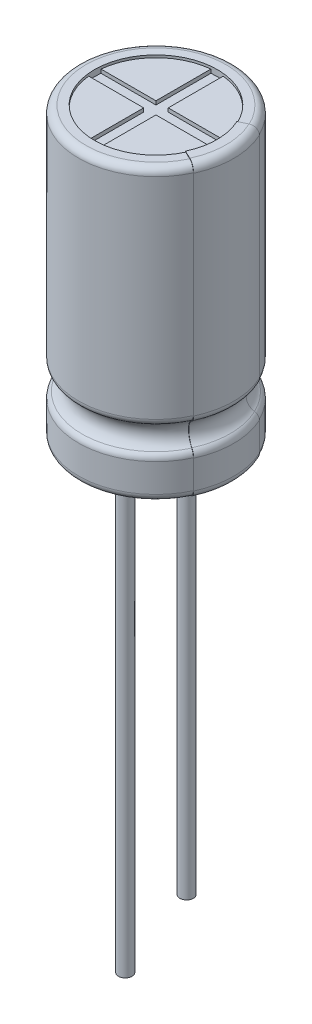
from build123d import *

# Parameters (mm, degrees)
BOSS_EXTRUDE1_DEPTH      = 0.15
BOSS_EXTRUDE1_2_DEPTH    = 0.15
BOSS_EXTRUDE1_3_DEPTH    = 0.15
BOSS_EXTRUDE1_4_DEPTH    = 0.15
SKETCH3_R                = 1.8
SKETCH3_RX               = 1.67
SKETCH3_RY               = 0.9
BOSS_EXTRUDE2_DEPTH      = 0.6
REVOLVE3_ANGLE           = 25
REVOLVE3_OTHER_WAY_ANGLE = 25
SKETCH7_R                = 0.275
BOSS_EXTRUDE3_DEPTH      = 19.6
SKETCH7_4_R              = 0.275
BOSS_EXTRUDE4_DEPTH      = 15.6


with BuildPart() as part:
    # Sketch1 → Revolve1 (revolve)
    with BuildSketch(Plane.XY, mode=Mode.PRIVATE) as revolve1_sk:
        with BuildLine():
            Line((0, 0.6), (2.55, 0.6))
            Line((2.55, 0.6), (2.55, 0.4))
            Line((2.55, 0.4), (2.85, 0.4))
            ThreePointArc((2.85, 0.4), (3.062132034, 0.487867966), (3.15, 0.7))
            Line((3.15, 0.7), (3.15, 1.856893734))
            ThreePointArc((3.15, 1.856893734), (3.113127589, 2.000990479), (3.011574188, 2.109665928))
            ThreePointArc((3.011574188, 2.109665928), (2.7430522, 2.6), (3.011574188, 3.090334072))
            ThreePointArc((3.011574188, 3.090334072), (3.113127589, 3.199009521), (3.15, 3.343106266))
            Line((3.15, 3.343106266), (3.15, 11.9))
            ThreePointArc((3.15, 11.9), (3.062132034, 12.112132034), (2.85, 12.2))
            Line((2.85, 12.2), (2.5, 12.2))
            Line((2.5, 12.2), (2.5, 11.95))
            Line((2.5, 11.95), (0, 11.95))
            Line((0, 11.95), (0, 0.6))
        make_face()
    revolve(revolve1_sk.sketch.rotate(Axis((0, 11.95, 0), (0, -1, 0)), 180), axis=Axis((0, 11.95, 0), (0, -1, 0)))



with BuildPart() as body_2:
    # Sketch2 → Boss-Extrude1 (new body)
    with BuildSketch(Plane(origin=(0, 11.95, 0), x_dir=(1, 0, 0), z_dir=(0, 1, 0))):
        with BuildLine():
            Line((-0.25, 0.25), (-0.25, 2.487468593))
            ThreePointArc((-0.25, 2.487468593), (-1.767766953, 1.767766953), (-2.487468593, 0.25))
            Line((-2.487468593, 0.25), (-0.25, 0.25))
        make_face()
    extrude(amount=BOSS_EXTRUDE1_DEPTH)


with BuildPart() as body_3:
    # Sketch2 → Boss-Extrude1 2 (new body)
    with BuildSketch(Plane(origin=(0, 11.95, 0), x_dir=(1, 0, 0), z_dir=(0, 1, 0))):
        with BuildLine():
            Line((0.25, -2.487468593), (0.25, -0.25))
            Line((0.25, -0.25), (2.487468593, -0.25))
            ThreePointArc((2.487468593, -0.25), (1.767766953, -1.767766953), (0.25, -2.487468593))
        make_face()
    extrude(amount=BOSS_EXTRUDE1_2_DEPTH)


with BuildPart() as body_4:
    # Sketch2 → Boss-Extrude1 3 (new body)
    with BuildSketch(Plane(origin=(0, 11.95, 0), x_dir=(1, 0, 0), z_dir=(0, 1, 0))):
        with BuildLine():
            Line((-0.25, -2.487468593), (-0.25, -0.25))
            Line((-0.25, -0.25), (-2.487468593, -0.25))
            ThreePointArc((-2.487468593, -0.25), (-1.767766953, -1.767766953), (-0.25, -2.487468593))
        make_face()
    extrude(amount=BOSS_EXTRUDE1_3_DEPTH)


with BuildPart() as body_5:
    # Sketch2 → Boss-Extrude1 4 (new body)
    with BuildSketch(Plane(origin=(0, 11.95, 0), x_dir=(1, 0, 0), z_dir=(0, 1, 0))):
        with BuildLine():
            Line((0.25, 0.25), (0.25, 2.487468593))
            ThreePointArc((0.25, 2.487468593), (1.767766953, 1.767766953), (2.487468593, 0.25))
            Line((2.487468593, 0.25), (0.25, 0.25))
        make_face()
    extrude(amount=BOSS_EXTRUDE1_4_DEPTH)


with BuildPart() as body_6:
    # Sketch3 → Boss-Extrude2 (new body)
    with BuildSketch(Plane.XZ.offset(-0.6)):
        Circle(SKETCH3_R)
        with Locations(Location((0, 0), (0, 0, 180))):
            Ellipse(SKETCH3_RX, SKETCH3_RY, mode=Mode.SUBTRACT)
    extrude(amount=BOSS_EXTRUDE2_DEPTH)


with BuildPart() as body_7:
    # Sketch5 → Revolve3 (revolve)
    with BuildSketch(Plane.XY):
        with BuildLine():
            Line((2.479915075, 12.22), (2.530084566, 0.38))
            Line((2.530084566, 0.38), (2.85, 0.38))
            ThreePointArc((2.85, 0.38), (3.07627417, 0.47372583), (3.17, 0.7))
            Line((3.17, 0.7), (3.17, 1.856893734))
            ThreePointArc((3.17, 1.856893734), (3.130669429, 2.010596928), (3.022345801, 2.126517407))
            ThreePointArc((3.022345801, 2.126517407), (2.7630522, 2.6), (3.022345801, 3.073482593))
            ThreePointArc((3.022345801, 3.073482593), (3.130669429, 3.189403072), (3.17, 3.343106266))
            Line((3.17, 3.343106266), (3.17, 11.9))
            ThreePointArc((3.17, 11.9), (3.07627417, 12.12627417), (2.85, 12.22))
            Line((2.85, 12.22), (2.479915075, 12.22))
        make_face()
        with BuildLine():
            Line((2.5, 12.2), (2.85, 12.2))
            ThreePointArc((2.85, 12.2), (3.062132034, 12.112132034), (3.15, 11.9))
            Line((3.15, 11.9), (3.15, 3.343106266))
            ThreePointArc((3.15, 3.343106266), (3.113127589, 3.199009521), (3.011574188, 3.090334072))
            ThreePointArc((3.011574188, 3.090334072), (2.7430522, 2.6), (3.011574188, 2.109665928))
            ThreePointArc((3.011574188, 2.109665928), (3.113127589, 2.000990479), (3.15, 1.856893734))
            Line((3.15, 1.856893734), (3.15, 0.7))
            ThreePointArc((3.15, 0.7), (3.062132034, 0.487867966), (2.85, 0.4))
            Line((2.85, 0.4), (2.55, 0.4))
            Line((2.55, 0.4), (2.5, 12.2))
        make_face(mode=Mode.SUBTRACT)
    revolve(axis=Axis((0, 0, 0), (0, 1, 0)), revolution_arc=REVOLVE3_ANGLE)

    # Sketch5 → Revolve3 other way (revolve)
    with BuildSketch(Plane.XY):
        with BuildLine():
            Line((2.479915075, 12.22), (2.530084566, 0.38))
            Line((2.530084566, 0.38), (2.85, 0.38))
            ThreePointArc((2.85, 0.38), (3.07627417, 0.47372583), (3.17, 0.7))
            Line((3.17, 0.7), (3.17, 1.856893734))
            ThreePointArc((3.17, 1.856893734), (3.130669429, 2.010596928), (3.022345801, 2.126517407))
            ThreePointArc((3.022345801, 2.126517407), (2.7630522, 2.6), (3.022345801, 3.073482593))
            ThreePointArc((3.022345801, 3.073482593), (3.130669429, 3.189403072), (3.17, 3.343106266))
            Line((3.17, 3.343106266), (3.17, 11.9))
            ThreePointArc((3.17, 11.9), (3.07627417, 12.12627417), (2.85, 12.22))
            Line((2.85, 12.22), (2.479915075, 12.22))
        make_face()
        with BuildLine():
            Line((2.5, 12.2), (2.85, 12.2))
            ThreePointArc((2.85, 12.2), (3.062132034, 12.112132034), (3.15, 11.9))
            Line((3.15, 11.9), (3.15, 3.343106266))
            ThreePointArc((3.15, 3.343106266), (3.113127589, 3.199009521), (3.011574188, 3.090334072))
            ThreePointArc((3.011574188, 3.090334072), (2.7430522, 2.6), (3.011574188, 2.109665928))
            ThreePointArc((3.011574188, 2.109665928), (3.113127589, 2.000990479), (3.15, 1.856893734))
            Line((3.15, 1.856893734), (3.15, 0.7))
            ThreePointArc((3.15, 0.7), (3.062132034, 0.487867966), (2.85, 0.4))
            Line((2.85, 0.4), (2.55, 0.4))
            Line((2.55, 0.4), (2.5, 12.2))
        make_face(mode=Mode.SUBTRACT)
    revolve(axis=Axis((0, 0, 0), (0, -1, 0)), revolution_arc=REVOLVE3_OTHER_WAY_ANGLE)


with BuildPart() as part_1:
    add(part.part)

    add(body_6.part)  # Boss-Extrude3 merges body 6
    # Sketch7 → Boss-Extrude3 (add)
    with BuildSketch(Plane.XZ.offset(-0.6)):
        with Locations(Location((-1.25, 0, 0), (0, 0, 180))):
            Circle(SKETCH7_R)
    extrude(amount=BOSS_EXTRUDE3_DEPTH)

    # Sketch7_4 → Boss-Extrude4 (add)
    with BuildSketch(Plane.XZ.offset(-0.6)):
        with Locations(Location((1.25, 0, 0), (0, 0, 180))):
            Circle(SKETCH7_4_R)
    extrude(amount=BOSS_EXTRUDE4_DEPTH)


solid = Compound([body_2.part, body_3.part, body_4.part, body_5.part, body_7.part, part_1.part])
